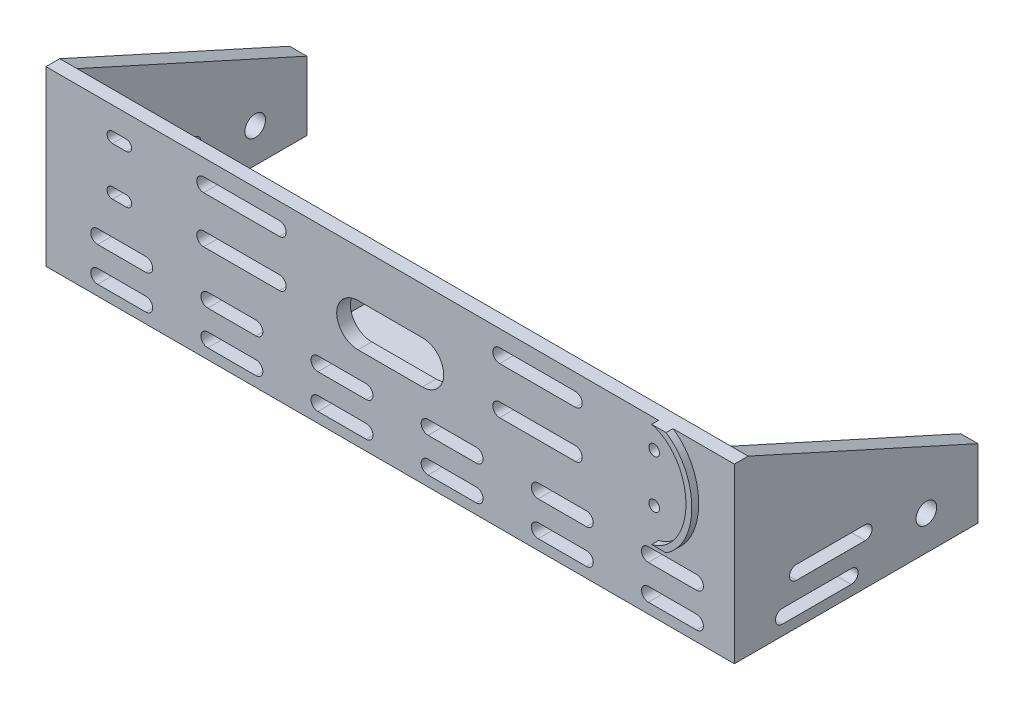
from build123d import *

# Parameters (mm, degrees)
SKETCH_1_W           = 200
SKETCH_1_H           = 200
EXTRUDE_1_DEPTH      = 4
SKETCH_2_W           = 200
SKETCH_2_H           = 200
CUT_EXTRUDE_1_DEPTH  = 10
CUT_EXTRUDE_2_DEPTH  = 10
SKETCH_4_R           = 1.2645
CUT_EXTRUDE_3_DEPTH  = 10
SKETCH_5_R           = 1.5645
SKETCH_5_R_2         = 1.2645
CUT_EXTRUDE_4_DEPTH  = 10
SKETCH_6_W           = 151.000000002
SKETCH_6_H           = 3
EXTRUDE_2_DEPTH      = 25
SKETCH_7_W           = 2
SKETCH_7_H           = 25
EXTRUDE_3_DEPTH      = 27.250481
CUT_EXTRUDE_5_DEPTH  = 155.418164294
SKETCH_9_W           = 25
SKETCH_9_H           = 3
EXTRUDE_4_DEPTH      = 19.5
SKETCH_10_W          = 25
SKETCH_10_H          = 3
EXTRUDE_5_DEPTH      = 19.5
SKETCH_11_R          = 1.5645
EXTRUDE_7_DEPTH      = 4
SKETCH_12_W          = 25
SKETCH_12_H          = 27.250481031
EXTRUDE_8_DEPTH      = 2
SKETCH_13_W          = 25
SKETCH_13_H          = 27.250481031
EXTRUDE_9_DEPTH      = 2
CUT_EXTRUDE_6_DEPTH  = 191.000000002
EXTRUDE_10_DEPTH     = 2
EXTRUDE_11_DEPTH     = 5
SKETCH_18_R          = 3
CUT_EXTRUDE_7_DEPTH  = 196.000000102
EXTRUDE_12_DEPTH     = 5
EXTRUDE_13_DEPTH     = 5
CUT_EXTRUDE_8_DEPTH  = 4
CUT_EXTRUDE_9_DEPTH  = 201.000000103
EXTRUDE_14_REACH     = 197
SKETCH_23_W          = 4
SKETCH_23_H          = 20
CUT_EXTRUDE_10_DEPTH = 4
CUT_EXTRUDE_11_DEPTH = 10
CUT_EXTRUDE_12_DEPTH = 2


with BuildPart() as part:
    # 草图1 → 凸台-拉伸1 (new body)
    with BuildSketch(Plane.XY):
        Rectangle(SKETCH_1_W, SKETCH_1_H)
    extrude(amount=EXTRUDE_1_DEPTH)

    # 草图2 → 切除-拉伸1 (cut)
    with BuildSketch(Plane.XY.offset(4)):
        Rectangle(SKETCH_2_W, SKETCH_2_H)
        with BuildLine():
            Line((-72.607629402, -10.530501842), (78.3923706, -10.530501842))
            add(Edge.make_bspline(
                [(78.3923706, -10.530501842), (78.393880387, -10.530501842), (78.399972524, -10.53049996), (78.40744519, -10.530491378), (78.459871908, -10.53038518), (78.562272047, -10.529406934), (78.709705475, -10.525745525), (78.867519351, -10.519395332), (79.011460862, -10.511271604), (79.163128689, -10.500500488), (79.314177324, -10.487542527), (79.48146243, -10.470336573), (79.625072974, -10.453078007), (79.714457573, -10.441104292), (79.828620547, -10.425256292), (80.06334743, -10.38961977), (80.447986875, -10.317063923), (80.804607354, -10.232716169), (81.010109931, -10.177223615), (81.271094972, -10.104267542), (81.653072128, -9.984548191), (82.204953821, -9.775873384), (82.733224047, -9.542742823), (83.080384914, -9.366425536), (83.363542253, -9.21272601), (83.594676625, -9.082189243), (83.944563941, -8.867794285), (84.303250262, -8.6290352), (84.536602386, -8.460897239), (84.67811474, -8.355000576), (84.868630399, -8.211197661), (85.217420243, -7.931169914), (85.693456263, -7.507965694), (86.160792675, -7.047893204), (86.463861613, -6.7174444), (86.705084475, -6.440891816), (86.900964007, -6.209064691), (87.089311918, -5.970595716), (87.276015542, -5.725693926), (87.363165679, -5.60758576), (87.566390889, -5.323258238), (87.807795061, -4.969931043), (88.153919224, -4.413295252), (88.489175038, -3.816720179), (88.696977954, -3.405825309), (88.827694465, -3.132985027), (88.961552796, -2.848834784), (89.186059359, -2.334343587), (89.452549767, -1.64230906), (89.611724622, -1.168522216), (89.709713744, -0.85457566), (89.732279416, -0.780564604), (89.818522908, -0.490886577), (89.938624245, -0.05740479), (90.042088798, 0.378887088), (90.130153117, 0.782983436), (90.218317016, 1.220249765), (90.306000365, 1.75393434), (90.388599777, 2.363273344), (90.454672066, 2.984147078), (90.505523692, 3.776258696), (90.517310025, 4.307283953), (90.517660945, 4.626339678), (90.517495564, 4.679554814), (90.515780492, 4.913414501), (90.507242486, 5.308832184), (90.486294809, 5.704553113), (90.458472193, 6.102064379), (90.420642115, 6.548963361), (90.352243586, 7.116156299), (90.254905763, 7.75569238), (90.139371739, 8.383847008), (89.968882042, 9.132540195), (89.834755229, 9.624444613), (89.712496066, 10.037493057), (89.659610942, 10.206799046), (89.584619088, 10.434523006), (89.498155072, 10.692437078), (89.405567032, 10.948461852), (89.25913666, 11.331116858), (89.091453274, 11.747163038), (88.907727045, 12.154890884), (88.709169844, 12.569926036), (88.509965198, 12.966174251), (88.184145506, 13.551639476), (87.825695748, 14.132919733), (87.570732294, 14.507134417), (87.306537888, 14.875920383), (87.169713303, 15.057612936), (87.007740906, 15.262115469), (86.85263991, 15.456477271), (86.556303726, 15.80793858), (86.125085813, 16.272847328), (85.824651865, 16.567072874), (85.641693274, 16.73762738), (85.483156881, 16.884005079), (85.320355757, 17.026808471), (85.140050328, 17.178288654), (84.960223922, 17.327161656), (84.776034828, 17.47097928), (84.610209439, 17.594731255), (84.414719243, 17.739353638), (84.046247727, 17.994801467), (83.693976719, 18.211827612), (83.35918282, 18.405532525), (83.199775918, 18.492622776), (82.958324133, 18.616725316), (82.721084383, 18.734959252), (82.47908929, 18.844576897), (82.28360727, 18.927283992), (82.122562456, 18.994454551), (81.830619699, 19.107790002), (81.438094679, 19.242379336), (81.174666844, 19.321024221), (81.003303504, 19.368456281), (80.874261012, 19.403327968), (80.687271896, 19.449919426), (80.452176284, 19.502940388), (80.217230736, 19.550401171), (79.952735177, 19.596492743), (79.686586193, 19.635507892), (79.480249043, 19.660045752), (79.27342215, 19.68086891), (79.066618193, 19.698045736), (78.778487967, 19.713854774), (78.563048758, 19.719177203), (78.441003264, 19.719867831), (78.425010406, 19.719925663), (78.4128902, 19.719962538), (78.400358023, 19.719976759), (78.3923706, 19.719979189)],
                knots=[0, 0, 0, 0, 4.447e-06, 1.5952e-05, 1.5952e-05, 0.000131611, 0.000272563, 0.000410637, 0.000581314, 0.00070686, 0.000885671, 0.001065892, 0.001244714, 0.001336472, 0.001336472, 0.001585108, 0.002037521, 0.002493259, 0.002672945, 0.002672945, 0.003303658, 0.003873505, 0.00444715, 0.005038552, 0.005038552, 0.005407894, 0.005828832, 0.006253752, 0.006682362, 0.006682362, 0.006780489, 0.007393979, 0.008018835, 0.008687071, 0.009355307, 0.009355307, 0.009778014, 0.010255315, 0.010255315, 0.010691779, 0.010691779, 0.01129905, 0.011973463, 0.012664373, 0.013364724, 0.013364724, 0.013578175, 0.014313322, 0.015058072, 0.015807425, 0.015807425, 0.016037669, 0.016037669, 0.016705905, 0.017374142, 0.017374142, 0.017943202, 0.018710614, 0.018998715, 0.019792218, 0.020588614, 0.021383559, 0.021383559, 0.021542504, 0.021542504, 0.022081494, 0.022720031, 0.022720031, 0.023266882, 0.024056504, 0.024428116, 0.025204624, 0.025971416, 0.026729449, 0.026729449, 0.027257473, 0.027257473, 0.02744224, 0.028065921, 0.028065921, 0.028660696, 0.029402393, 0.029402393, 0.030037035, 0.030729842, 0.031407102, 0.032075338, 0.032075338, 0.032751059, 0.032751059, 0.032851788, 0.033491451, 0.034123241, 0.034748283, 0.034748283, 0.034869809, 0.035391849, 0.035391849, 0.035569072, 0.036084756, 0.036084756, 0.036183433, 0.036807161, 0.037421228, 0.037421228, 0.037965125, 0.037965125, 0.038233217, 0.0387577, 0.0387577, 0.038864727, 0.039276448, 0.039685838, 0.040094173, 0.040094173, 0.04021696, 0.040496337, 0.040685967, 0.040968695, 0.041251278, 0.041532222, 0.041808011, 0.041886525, 0.042155666, 0.042417837, 0.042701929, 0.042736406, 0.042736406, 0.042743529, 0.042767118, 0.042767118, 0.042767118, 0.042767118], degree=3, weights=[1, 1, 1, 1, 1, 1, 1, 1, 1, 1, 1, 1, 1, 1, 1, 1, 1, 1, 1, 1, 1, 1, 1, 1, 1, 1, 1, 1, 1, 1, 1, 1, 1, 1, 1, 1, 1, 1, 1, 1, 1, 1, 1, 1, 1, 1, 1, 1, 1, 1, 1, 1, 1, 1, 1, 1, 1, 1, 1, 1, 1, 1, 1, 1, 1, 1, 1, 1, 1, 1, 1, 1, 1, 1, 1, 1, 1, 1, 1, 1, 1, 1, 1, 1, 1, 1, 1, 1, 1, 1, 1, 1, 1, 1, 1, 1, 1, 1, 1, 1, 1, 1, 1, 1, 1, 1, 1, 1, 1, 1, 1, 1, 1, 1, 1, 1, 1, 1, 1, 1, 1, 1, 1, 1, 1, 1, 1, 1, 1, 1, 1]))
            Line((78.3923706, 19.719979189), (-72.607629375, 19.719979189))
            add(Edge.make_bspline(
                [(-72.607629375, 19.719979189), (-72.609120172, 19.719979189), (-72.615171425, 19.719977341), (-72.62260188, 19.719968873), (-72.674722096, 19.719863926), (-72.776500065, 19.718897604), (-72.922708191, 19.71528854), (-73.079630746, 19.709020561), (-73.221910336, 19.701044557), (-73.372528292, 19.690430873), (-73.522502111, 19.677670516), (-73.689585503, 19.66060575), (-73.834809521, 19.643262006), (-73.926008075, 19.63109031), (-74.054727497, 19.613244863), (-74.293398118, 19.576584571), (-74.673465953, 19.503972802), (-75.01776578, 19.422625292), (-75.229158928, 19.365730944), (-75.301013956, 19.345543089), (-75.491311986, 19.291769051), (-75.857952952, 19.177121545), (-76.394457744, 18.976048344), (-76.926450095, 18.74254787), (-77.270811247, 18.568708782), (-77.540701481, 18.423189414), (-77.637731563, 18.368965121), (-77.859072885, 18.2408852), (-78.107287227, 18.090773474), (-78.467542626, 17.853600754), (-78.699867305, 17.688065511), (-78.833646464, 17.589153364), (-78.894320312, 17.543973614), (-79.088218209, 17.396702668), (-79.418377197, 17.131546447), (-79.861509288, 16.741153034), (-80.322082784, 16.292594649), (-80.619611571, 15.97235732), (-80.800646018, 15.767656173), (-80.835411621, 15.72787809), (-80.929758666, 15.618647104), (-81.097498586, 15.420442812), (-81.260079723, 15.216905528), (-81.463806874, 14.952213818), (-81.56231914, 14.819436441), (-81.689441537, 14.641825954), (-81.846409356, 14.419911538), (-82.124048959, 14.003054946), (-82.474431564, 13.422341759), (-82.774927648, 12.869904628), (-82.952816885, 12.51129492), (-83.102842739, 12.196649736), (-83.28205453, 11.804116753), (-83.446311209, 11.403633346), (-83.554879079, 11.121127163), (-83.609425129, 10.977297275), (-83.724594662, 10.660780526), (-83.815965555, 10.388727362), (-83.899969269, 10.125009541), (-83.937326505, 10.004370771), (-83.992432836, 9.819431857), (-84.073418882, 9.539048513), (-84.205057372, 9.042806728), (-84.359731928, 8.358462719), (-84.489986682, 7.645654594), (-84.590008199, 6.949971231), (-84.666177716, 6.24153145), (-84.717769727, 5.480511163), (-84.731462381, 4.947673985), (-84.732804636, 4.652175983), (-84.732869903, 4.623460211), (-84.732869903, 4.399700787), (-84.724780485, 3.876033569), (-84.676451959, 3.026094093), (-84.605354506, 2.374991648), (-84.552317644, 1.984296696), (-84.531797655, 1.838965975), (-84.470652269, 1.439913557), (-84.365296997, 0.858149211), (-84.198088679, 0.1134157), (-84.066183036, -0.376791513), (-83.985356037, -0.653412822), (-83.94528144, -0.78904762), (-83.903561265, -0.924255641), (-83.856678433, -1.071437688), (-83.767903648, -1.346180595), (-83.657581065, -1.660670459), (-83.556966369, -1.926126885), (-83.490484775, -2.099464784), (-83.346860633, -2.460440149), (-83.092677136, -3.03987542), (-82.772156641, -3.689159713), (-82.541583464, -4.107576984), (-82.400079699, -4.351103033), (-82.33318256, -4.464984105), (-82.175042356, -4.726375788), (-81.943600871, -5.087804529), (-81.747373232, -5.371765216), (-81.554675873, -5.640268291), (-81.459818679, -5.767918147), (-81.295390674, -5.981550655), (-81.095933069, -6.234420659), (-80.753626087, -6.63849695), (-80.327817351, -7.096021609), (-80.031026024, -7.386074809), (-79.773444849, -7.625828705), (-79.553653616, -7.823527688), (-79.20802993, -8.112912422), (-78.967610443, -8.29936161), (-78.655180789, -8.532138954), (-78.289277614, -8.7882164), (-77.909858247, -9.022127083), (-77.633289044, -9.181954844), (-77.538577346, -9.234857366), (-77.297562624, -9.364807638), (-76.99626455, -9.518534706), (-76.686647679, -9.658465977), (-76.399558623, -9.779729146), (-76.126068138, -9.889012513), (-75.701455126, -10.038178146), (-75.403324171, -10.127907614), (-75.176711301, -10.190532329), (-75.021102618, -10.231518747), (-74.791406143, -10.286310703), (-74.561033552, -10.335582961), (-74.330661775, -10.37924555), (-74.099073179, -10.41753804), (-73.89735567, -10.446010512), (-73.693381846, -10.470832691), (-73.487778575, -10.491920853), (-73.222930145, -10.51247218), (-72.957558651, -10.525576619), (-72.748362443, -10.52992818), (-72.647161877, -10.530442073), (-72.626361276, -10.530483957), (-72.619630604, -10.530496181), (-72.612207573, -10.530501842), (-72.607629402, -10.530501842)],
                knots=[0, 0, 0, 0, 4.386e-06, 1.5837e-05, 1.5837e-05, 0.000130651, 0.000270539, 0.000406605, 0.000576914, 0.000698994, 0.000877449, 0.001057414, 0.001236053, 0.001333619, 0.001333619, 0.001619655, 0.002045827, 0.002474984, 0.002667238, 0.002697787, 0.002697787, 0.003257622, 0.003848006, 0.004419103, 0.005003058, 0.005003058, 0.005334476, 0.005334476, 0.005764302, 0.006194128, 0.006608374, 0.006608374, 0.006688166, 0.006833182, 0.007332751, 0.00795098, 0.008598759, 0.00925525, 0.00925525, 0.009412489, 0.009412489, 0.009684356, 0.010183078, 0.010183078, 0.010672665, 0.010672665, 0.010831853, 0.011480628, 0.012166043, 0.012861197, 0.013365174, 0.013365174, 0.013904734, 0.014655834, 0.014655834, 0.014804903, 0.015113025, 0.015654973, 0.015654973, 0.015934148, 0.016030033, 0.016229494, 0.016804016, 0.017563946, 0.018332232, 0.018979733, 0.019674424, 0.020469263, 0.021261019, 0.021261019, 0.021346201, 0.021346201, 0.02192464, 0.022901272, 0.023881232, 0.023881232, 0.024080954, 0.024320504, 0.025089618, 0.025850088, 0.026599857, 0.026599857, 0.026705278, 0.027019343, 0.027019343, 0.027163228, 0.027875464, 0.028008671, 0.028008671, 0.028428639, 0.029167228, 0.029898321, 0.030591383, 0.030591383, 0.030736472, 0.030984281, 0.031498114, 0.032006855, 0.032006855, 0.032479846, 0.032479846, 0.032809184, 0.033439298, 0.034060241, 0.034674093, 0.034674093, 0.03510479, 0.03554946, 0.036007712, 0.036007712, 0.036710162, 0.037341331, 0.037341331, 0.03766566, 0.03766566, 0.03815906, 0.038674949, 0.038674949, 0.039081393, 0.03954613, 0.040008568, 0.040008568, 0.040249231, 0.040500362, 0.040754679, 0.041009689, 0.041263098, 0.041513325, 0.04165497, 0.041897483, 0.042132476, 0.042413821, 0.042612079, 0.042659983, 0.042659983, 0.04266232, 0.042675806, 0.042675806, 0.042675806, 0.042675806], degree=3, weights=[1, 1, 1, 1, 1, 1, 1, 1, 1, 1, 1, 1, 1, 1, 1, 1, 1, 1, 1, 1, 1, 1, 1, 1, 1, 1, 1, 1, 1, 1, 1, 1, 1, 1, 1, 1, 1, 1, 1, 1, 1, 1, 1, 1, 1, 1, 1, 1, 1, 1, 1, 1, 1, 1, 1, 1, 1, 1, 1, 1, 1, 1, 1, 1, 1, 1, 1, 1, 1, 1, 1, 1, 1, 1, 1, 1, 1, 1, 1, 1, 1, 1, 1, 1, 1, 1, 1, 1, 1, 1, 1, 1, 1, 1, 1, 1, 1, 1, 1, 1, 1, 1, 1, 1, 1, 1, 1, 1, 1, 1, 1, 1, 1, 1, 1, 1, 1, 1, 1, 1, 1, 1, 1, 1, 1, 1, 1, 1, 1, 1, 1, 1, 1, 1, 1, 1, 1, 1]))
        make_face(mode=Mode.SUBTRACT)
    extrude(amount=-CUT_EXTRUDE_1_DEPTH, mode=Mode.SUBTRACT)

    # 草图3 → 切除-拉伸2 (cut)
    with BuildSketch(Plane(origin=(0, 0, 0), x_dir=(-1, 0, 0), z_dir=(0, 0, -1))):
        with BuildLine():
            Line((-12.242370643, -6.205261327), (6.457629357, -6.205261327))
            ThreePointArc((6.457629357, -6.205261327), (12.657629357, -0.005261327), (6.457629357, 6.194738673))
            Line((6.457629357, 6.194738673), (-12.242370643, 6.194738673))
            ThreePointArc((-12.242370643, 6.194738673), (-18.442370643, -0.005261327), (-12.242370643, -6.205261327))
        make_face()
    extrude(amount=-CUT_EXTRUDE_2_DEPTH, mode=Mode.SUBTRACT)

    # 草图4 → 切除-拉伸3 (cut)
    with BuildSketch(Plane(origin=(0, 0, 0), x_dir=(-1, 0, 0), z_dir=(0, 0, -1))):
        with Locations((-79.592370643, 11.594738673)):
            Circle(SKETCH_4_R)
        with Locations((-79.592370643, -2.405261327)):
            Circle(SKETCH_4_R)
        with Locations((73.807629357, 11.594738673)):
            Circle(SKETCH_4_R)
        with Locations((73.807629357, -2.405261327)):
            Circle(SKETCH_4_R)
    extrude(amount=-CUT_EXTRUDE_3_DEPTH, mode=Mode.SUBTRACT)

    # 草图5 → 切除-拉伸4 (cut)
    with BuildSketch(Plane(origin=(0, 0, 0), x_dir=(-1, 0, 0), z_dir=(0, 0, -1))):
        with Locations((73.807629357, 11.594738673)):
            Circle(SKETCH_5_R)
        with Locations((73.807629357, 11.594738673)):
            Circle(SKETCH_5_R_2, mode=Mode.SUBTRACT)
        with Locations((73.807629357, -2.405261327)):
            Circle(SKETCH_5_R)
        with Locations((73.807629357, -2.405261327)):
            Circle(SKETCH_5_R_2, mode=Mode.SUBTRACT)
        with Locations((-79.592370643, -2.405261327)):
            Circle(SKETCH_5_R)
        with Locations((-79.592370643, 11.594738673)):
            Circle(SKETCH_5_R)
    extrude(amount=-CUT_EXTRUDE_4_DEPTH, mode=Mode.SUBTRACT)

    # 草图6 → 凸台-拉伸2 (add)
    with BuildSketch(Plane(origin=(0, 0, 0), x_dir=(-1, 0, 0), z_dir=(0, 0, -1))):
        with Locations((-2.892370599, -9.030501842)):
            Rectangle(SKETCH_6_W, SKETCH_6_H)
    extrude(amount=EXTRUDE_2_DEPTH)

    # 草图7 → 凸台-拉伸3 (add)
    with BuildSketch(Plane(origin=(0, -7.530501842, 0), x_dir=(1, 0, 0), z_dir=(0, 1, 0))):
        with Locations((24.685294291, 12.5)):
            Rectangle(SKETCH_7_W, SKETCH_7_H)
        with Locations((68.685294291, 12.5)):
            Rectangle(SKETCH_7_W, SKETCH_7_H)
        with Locations((-19.314705709, 12.5)):
            Rectangle(SKETCH_7_W, SKETCH_7_H)
        with Locations((-63.314705709, 12.5)):
            Rectangle(SKETCH_7_W, SKETCH_7_H)
    extrude(amount=EXTRUDE_3_DEPTH)

    # 草图8 → 切除-拉伸5 (cut, through all)
    with BuildSketch(Plane(origin=(69.685294291, 0, 0), x_dir=(0, 0, -1), z_dir=(1, 0, 0))):
        Polygon((0, 19.719979189), (25, -7.530501842), (25, 19.719979189), align=None)
    extrude(amount=-CUT_EXTRUDE_5_DEPTH, mode=Mode.SUBTRACT)

    # 草图9 → 凸台-拉伸4 (add)
    with BuildSketch(Plane(origin=(78.3923706, 0, 0), x_dir=(0, 0, -1), z_dir=(1, 0, 0))):
        with Locations((12.5, -9.030501842)):
            Rectangle(SKETCH_9_W, SKETCH_9_H)
    extrude(amount=EXTRUDE_4_DEPTH)

    # 草图10 → 凸台-拉伸5 (add)
    with BuildSketch(Plane.ZY.offset(72.607629402)):
        with Locations((-12.5, -9.030501842)):
            Rectangle(SKETCH_10_W, SKETCH_10_H)
    extrude(amount=EXTRUDE_5_DEPTH)

    # 草图11 → 凸台-拉伸7 (add)
    with BuildSketch(Plane(origin=(0, 0, 0), x_dir=(-1, 0, 0), z_dir=(0, 0, -1))):
        with BuildLine():
            Line((-85.66125426, -7.530501842), (-69.685294291, -7.530501842))
            Line((-69.685294291, -7.530501842), (-69.685294291, 19.719979189))
            Line((-69.685294291, 19.719979189), (-78.3923706, 19.719979189))
            Line((-78.3923706, 19.719979189), (-97.8923706, 19.719979189))
            Line((-97.8923706, 19.719979189), (-97.8923706, -7.530501842))
            Line((-97.8923706, -7.530501842), (-97.8923706, -10.530501842))
            Line((-97.8923706, -10.530501842), (-78.3923706, -10.530501842))
            add(Edge.make_bspline(
                [(-78.3923706, -10.530501842), (-78.393880387, -10.530501842), (-78.399972524, -10.53049996), (-78.40744519, -10.530491378), (-78.459871908, -10.53038518), (-78.562272047, -10.529406934), (-78.709705475, -10.525745525), (-78.867519351, -10.519395332), (-79.011460862, -10.511271604), (-79.163128689, -10.500500488), (-79.314177324, -10.487542527), (-79.48146243, -10.470336573), (-79.625072974, -10.453078007), (-79.714457573, -10.441104292), (-79.828620547, -10.425256292), (-80.06334743, -10.38961977), (-80.447986875, -10.317063923), (-80.804607354, -10.232716169), (-81.010109931, -10.177223615), (-81.271094972, -10.104267542), (-81.653072128, -9.984548191), (-82.204953821, -9.775873384), (-82.733224047, -9.542742823), (-83.080384914, -9.366425536), (-83.363542253, -9.21272601), (-83.594676625, -9.082189243), (-83.944563941, -8.867794285), (-84.303250262, -8.6290352), (-84.536602386, -8.460897239), (-84.67811474, -8.355000576), (-84.868630399, -8.211197661), (-85.211038803, -7.936293286), (-85.514395007, -7.667143377), (-85.66125426, -7.530501842)],
                knots=[0, 0, 0, 0, 4.447e-06, 1.5952e-05, 1.5952e-05, 0.000131611, 0.000272563, 0.000410637, 0.000581314, 0.00070686, 0.000885671, 0.001065892, 0.001244714, 0.001336472, 0.001336472, 0.001585108, 0.002037521, 0.002493259, 0.002672945, 0.002672945, 0.003303658, 0.003873505, 0.00444715, 0.005038552, 0.005038552, 0.005407894, 0.005828832, 0.006253752, 0.006682362, 0.006682362, 0.006780489, 0.007393979, 0.007994383, 0.007994383, 0.007994383, 0.007994383], degree=3, weights=[1, 1, 1, 1, 1, 1, 1, 1, 1, 1, 1, 1, 1, 1, 1, 1, 1, 1, 1, 1, 1, 1, 1, 1, 1, 1, 1, 1, 1, 1, 1, 1, 1, 1]))
        make_face()
        with Locations((-79.592370643, 11.594738673)):
            Circle(SKETCH_11_R, mode=Mode.SUBTRACT)
        with Locations((-79.592370643, -2.405261327)):
            Circle(SKETCH_11_R, mode=Mode.SUBTRACT)
        with BuildLine():
            Line((64.314705709, -7.530501842), (79.875858344, -7.530501842))
            add(Edge.make_bspline(
                [(79.875858344, -7.530501842), (79.770869403, -7.628144797), (79.552324591, -7.824640458), (79.20802993, -8.112912422), (78.967610443, -8.29936161), (78.655180789, -8.532138954), (78.289277614, -8.7882164), (77.909858247, -9.022127083), (77.633289044, -9.181954844), (77.538577346, -9.234857366), (77.297562624, -9.364807638), (76.99626455, -9.518534706), (76.686647679, -9.658465977), (76.399558623, -9.779729146), (76.126068138, -9.889012513), (75.701455126, -10.038178146), (75.403324171, -10.127907614), (75.176711301, -10.190532329), (75.021102618, -10.231518747), (74.791406143, -10.286310703), (74.561033552, -10.335582961), (74.330661775, -10.37924555), (74.099073179, -10.41753804), (73.89735567, -10.446010512), (73.693381846, -10.470832691), (73.487778575, -10.491920853), (73.222930145, -10.51247218), (72.957558651, -10.525576619), (72.748362443, -10.52992818), (72.647161877, -10.530442073), (72.626361276, -10.530483957), (72.619630604, -10.530496181), (72.612207573, -10.530501842), (72.607629402, -10.530501842)],
                knots=[0.034679221, 0.034679221, 0.034679221, 0.034679221, 0.03510479, 0.03554946, 0.036007712, 0.036007712, 0.036710162, 0.037341331, 0.037341331, 0.03766566, 0.03766566, 0.03815906, 0.038674949, 0.038674949, 0.039081393, 0.03954613, 0.040008568, 0.040008568, 0.040249231, 0.040500362, 0.040754679, 0.041009689, 0.041263098, 0.041513325, 0.04165497, 0.041897483, 0.042132476, 0.042413821, 0.042612079, 0.042659983, 0.042659983, 0.04266232, 0.042675806, 0.042675806, 0.042675806, 0.042675806], degree=3, weights=[1, 1, 1, 1, 1, 1, 1, 1, 1, 1, 1, 1, 1, 1, 1, 1, 1, 1, 1, 1, 1, 1, 1, 1, 1, 1, 1, 1, 1, 1, 1, 1, 1, 1]))
            Line((72.607629402, -10.530501842), (92.107629402, -10.530501842))
            Line((92.107629402, -10.530501842), (92.107629402, -7.530501842))
            Line((92.107629402, -7.530501842), (92.107629402, 19.719979189))
            Line((92.107629402, 19.719979189), (72.607629375, 19.719979189))
            Line((72.607629375, 19.719979189), (64.314705709, 19.719979189))
            Line((64.314705709, 19.719979189), (64.314705709, -7.530501842))
        make_face()
        with Locations((73.807629357, 11.594738673)):
            Circle(SKETCH_11_R, mode=Mode.SUBTRACT)
        with Locations((73.807629357, -2.405261327)):
            Circle(SKETCH_11_R, mode=Mode.SUBTRACT)
    extrude(amount=-EXTRUDE_7_DEPTH)

    # 草图12 → 凸台-拉伸8 (add)
    with BuildSketch(Plane(origin=(97.8923706, 0, 0), x_dir=(0, 0, -1), z_dir=(1, 0, 0))):
        with Locations((12.5, 6.094738674)):
            Rectangle(SKETCH_12_W, SKETCH_12_H)
    extrude(amount=-EXTRUDE_8_DEPTH)

    # 草图13 → 凸台-拉伸9 (add)
    with BuildSketch(Plane.ZY.offset(92.107629402)):
        with Locations((-12.5, 6.094738674)):
            Rectangle(SKETCH_13_W, SKETCH_13_H)
    extrude(amount=-EXTRUDE_9_DEPTH)

    # 草图14 → 切除-拉伸6 (cut, through all)
    with BuildSketch(Plane(origin=(97.8923706, 0, 0), x_dir=(0, 0, -1), z_dir=(1, 0, 0))):
        Polygon((0, 19.719979189), (25, -7.530501842), (25, 19.719979189), align=None)
    extrude(amount=-CUT_EXTRUDE_6_DEPTH, mode=Mode.SUBTRACT)

    # 草图15 → 凸台-拉伸10 (add)
    with BuildSketch(Plane.XY.offset(4)):
        with BuildLine():
            Line((-79.26705605, 19.719979189), (-75.058434673, 19.719979189))
            add(Edge.make_bspline(
                [(-75.058434673, 19.719979189), (-75.160324056, 19.694782078), (-75.706631825, 19.55073791), (-76.667619967, 19.212740646), (-77.894801871, 18.599225082), (-79.05929198, 17.827608518), (-80.457770993, 16.653810185), (-82.577793934, 14.21129148), (-84.525164222, 10.031908238), (-85.285746269, 4.608084744), (-84.529383017, -0.844443534), (-82.563599876, -5.040814161), (-80.153651059, -7.815042068), (-78.299917073, -9.206466034), (-76.661547883, -10.027672966), (-75.672355915, -10.371321577), (-75.149732483, -10.507952082), (-75.058434673, -10.530501842)],
                knots=[0.002364279, 0.002364279, 0.002364279, 0.002364279, 0.002667238, 0.004000857, 0.005334476, 0.006668095, 0.008001714, 0.010668952, 0.016003427, 0.021337903, 0.026672379, 0.032006855, 0.034674093, 0.037341331, 0.038674949, 0.040008568, 0.0402934, 0.0402934, 0.0402934, 0.0402934], degree=3))
            Line((-75.058434673, -10.530501842), (-79.266786568, -10.530501842))
            add(Edge.make_bspline(
                [(-79.26705605, 19.719979189), (-79.37845755, 19.648360464), (-79.64671165, 19.470290181), (-80.33581099, 18.976873188), (-81.667415293, 17.858950291), (-83.36862655, 15.895091148), (-84.890999562, 13.285419124), (-86.324766244, 9.518904929), (-87.005377243, 4.611709431), (-86.187053889, -1.323076644), (-84.029814318, -5.946067173), (-81.546064588, -8.809855489), (-80.074224087, -9.996616822), (-79.376932823, -10.459655534), (-79.266786568, -10.530501842)],
                knots=[0.00585724, 0.00585724, 0.00585724, 0.00585724, 0.006190645, 0.006668095, 0.008001714, 0.010668952, 0.013336189, 0.016003427, 0.021337903, 0.026672379, 0.032006855, 0.034674093, 0.036473164, 0.036806569, 0.036806569, 0.036806569, 0.036806569], degree=3))
        make_face()
        with BuildLine():
            Line((80.843175871, -10.530501842), (85.051527766, -10.530501842))
            add(Edge.make_bspline(
                [(85.051797248, 19.719979189), (85.163198748, 19.648360464), (85.431452848, 19.470290181), (86.120552188, 18.976873188), (87.452156491, 17.858950291), (89.153367748, 15.895091148), (90.67574076, 13.285419124), (92.109507442, 9.518904929), (92.790118441, 4.611709431), (91.971795087, -1.323076644), (89.814555516, -5.946067173), (87.330805785, -8.809855489), (85.858965285, -9.996616822), (85.161674021, -10.459655534), (85.051527766, -10.530501842)],
                knots=[0.00585724, 0.00585724, 0.00585724, 0.00585724, 0.006190645, 0.006668095, 0.008001714, 0.010668952, 0.013336189, 0.016003427, 0.021337903, 0.026672379, 0.032006855, 0.034674093, 0.036473164, 0.036806569, 0.036806569, 0.036806569, 0.036806569], degree=3))
            Line((85.051797248, 19.719979189), (80.843175871, 19.719979189))
            add(Edge.make_bspline(
                [(80.843175871, 19.719979189), (80.945065254, 19.694782078), (81.491373022, 19.55073791), (82.452361165, 19.212740646), (83.679543068, 18.599225082), (84.844033178, 17.827608518), (86.242512191, 16.653810185), (88.362535131, 14.21129148), (90.30990542, 10.031908238), (91.070487467, 4.608084744), (90.314124215, -0.844443534), (88.348341074, -5.040814161), (85.938392257, -7.815042068), (84.08465827, -9.206466034), (82.446289081, -10.027672966), (81.457097112, -10.371321577), (80.934473681, -10.507952082), (80.843175871, -10.530501842)],
                knots=[0.002364279, 0.002364279, 0.002364279, 0.002364279, 0.002667238, 0.004000857, 0.005334476, 0.006668095, 0.008001714, 0.010668952, 0.016003427, 0.021337903, 0.026672379, 0.032006855, 0.034674093, 0.037341331, 0.038674949, 0.040008568, 0.0402934, 0.0402934, 0.0402934, 0.0402934], degree=3))
        make_face()
    extrude(amount=EXTRUDE_10_DEPTH)

    # 草图17 → 凸台-拉伸11 (add)
    with BuildSketch(Plane(origin=(97.8923706, 0, 0), x_dir=(0, 0, -1), z_dir=(1, 0, 0))):
        Polygon((66.781558099, -30.530501842), (66.781558099, -10.530501842), (25, -10.530501842), (25, -7.530501842), (0, 19.719979189), (-4, 19.719979189), (-4, -10.530501842), (-4, -30.530501842), align=None)
    extrude_11 = extrude(amount=EXTRUDE_11_DEPTH)

    # 草图18 → 切除-拉伸7 (cut, through all)
    with BuildSketch(Plane(origin=(102.8923706, 0, 0), x_dir=(0, 0, -1), z_dir=(1, 0, 0))):
        with Locations((51.781558099, -20.530501842)):
            Circle(SKETCH_18_R)
    cut_extrude_7 = extrude(amount=-CUT_EXTRUDE_7_DEPTH, mode=Mode.SUBTRACT)

    # 镜向1: 凸台-拉伸11, 切除-拉伸7 across plane
    add(extrude_11.mirror(Plane.ZY.offset(-2.892370598)))
    add(cut_extrude_7.mirror(Plane.ZY.offset(-2.892370598)), mode=Mode.SUBTRACT)

    # 草图19 → 凸台-拉伸12 (add)
    with BuildSketch(Plane(origin=(102.8923706, 0, 0), x_dir=(0, 0, -1), z_dir=(1, 0, 0))):
        Polygon((0, 19.719979189), (66.781558099, -10.530501842), (25, -10.530501842), (25, -7.530501842), align=None)
    extrude(amount=-EXTRUDE_12_DEPTH)

    # 草图20 → 凸台-拉伸13 (add)
    with BuildSketch(Plane.ZY.offset(97.107629404)):
        Polygon((-66.781558099, -10.530501842), (0, 19.719979189), (-25, -7.530501842), (-25, -10.530501842), align=None)
    extrude(amount=-EXTRUDE_13_DEPTH)

    # 草图21 → 切除-拉伸8 (cut)
    with BuildSketch(Plane(origin=(0, 0, 0), x_dir=(-1, 0, 0), z_dir=(0, 0, -1))):
        with BuildLine():
            Line((-56.685294291, 14.907358931), (-34.685294291, 14.907358931))
            ThreePointArc((-34.685294291, 14.907358931), (-32.685294291, 12.907358931), (-34.685294291, 10.907358931))
            Line((-34.685294291, 10.907358931), (-56.685294291, 10.907358931))
            ThreePointArc((-56.685294291, 10.907358931), (-58.685294291, 12.907358931), (-56.685294291, 14.907358931))
        make_face()
        with BuildLine():
            Line((-56.685294291, -2.717881584), (-34.685294291, -2.717881584))
            ThreePointArc((-34.685294291, -2.717881584), (-32.685294291, -0.717881584), (-34.685294291, 1.282118416))
            Line((-34.685294291, 1.282118416), (-56.685294291, 1.282118416))
            ThreePointArc((-56.685294291, 1.282118416), (-58.685294291, -0.717881584), (-56.685294291, -2.717881584))
        make_face()
        with BuildLine():
            Line((51.314705709, -2.717881584), (29.314705709, -2.717881584))
            ThreePointArc((29.314705709, -2.717881584), (27.314705709, -0.717881584), (29.314705709, 1.282118416))
            Line((29.314705709, 1.282118416), (51.314705709, 1.282118416))
            ThreePointArc((51.314705709, 1.282118416), (53.314705709, -0.717881584), (51.314705709, -2.717881584))
        make_face()
        with BuildLine():
            Line((51.314705709, 14.907358931), (29.314705709, 14.907358931))
            ThreePointArc((29.314705709, 14.907358931), (27.314705709, 12.907358931), (29.314705709, 10.907358931))
            Line((29.314705709, 10.907358931), (51.314705709, 10.907358931))
            ThreePointArc((51.314705709, 10.907358931), (53.314705709, 12.907358931), (51.314705709, 14.907358931))
        make_face()
    extrude(amount=-CUT_EXTRUDE_8_DEPTH, mode=Mode.SUBTRACT)

    # 草图22 → 切除-拉伸9 (cut, through all)
    with BuildSketch(Plane(origin=(102.8923706, 0, 0), x_dir=(0, 0, -1), z_dir=(1, 0, 0))):
        with BuildLine():
            Line((9.945389525, -23.530501842), (29.945389525, -23.530501842))
            ThreePointArc((29.945389525, -23.530501842), (31.945389525, -25.530501842), (29.945389525, -27.530501842))
            Line((29.945389525, -27.530501842), (9.945389525, -27.530501842))
            ThreePointArc((9.945389525, -27.530501842), (7.945389525, -25.530501842), (9.945389525, -23.530501842))
        make_face()
        with BuildLine():
            Line((14.01752414, -14.540777212), (34.01752414, -14.540777212))
            ThreePointArc((34.01752414, -14.540777212), (36.01752414, -16.540777212), (34.01752414, -18.540777212))
            Line((34.01752414, -18.540777212), (14.01752414, -18.540777212))
            ThreePointArc((14.01752414, -18.540777212), (12.01752414, -16.540777212), (14.01752414, -14.540777212))
        make_face()
    extrude(amount=-CUT_EXTRUDE_9_DEPTH, mode=Mode.SUBTRACT)

    # 草图23 → 凸台-拉伸14 (add, up to next)
    with BuildSketch(Plane.ZY.offset(-97.8923706), mode=Mode.PRIVATE) as extrude_14_sk1:
        with Locations((2, -20.530501842)):
            Rectangle(SKETCH_23_W, SKETCH_23_H)
    extrude_14_tool1 = extrude(extrude_14_sk1.sketch, amount=EXTRUDE_14_REACH, mode=Mode.PRIVATE) - part.part
    add(extrude_14_tool1.solids().sort_by_distance((97.892371, -20.530502, 2))[0])

    # 草图24 → 切除-拉伸10 (cut)
    with BuildSketch(Plane.XY.offset(4)):
        with BuildLine():
            Line((-82.107629402, -23.530501842), (-68.107629402, -23.530501842))
            ThreePointArc((-68.107629402, -23.530501842), (-66.107629402, -25.530501842), (-68.107629402, -27.530501842))
            Line((-68.107629402, -27.530501842), (-82.107629402, -27.530501842))
            ThreePointArc((-82.107629402, -27.530501842), (-84.107629402, -25.530501842), (-82.107629402, -23.530501842))
        make_face()
        with BuildLine():
            Line((-82.107629402, -17.530501842), (-68.107629402, -17.530501842))
            ThreePointArc((-68.107629402, -17.530501842), (-66.107629402, -15.530501842), (-68.107629402, -13.530501842))
            Line((-68.107629402, -13.530501842), (-82.107629402, -13.530501842))
            ThreePointArc((-82.107629402, -13.530501842), (-84.107629402, -15.530501842), (-82.107629402, -17.530501842))
        make_face()
        with BuildLine():
            Line((-50.107629402, -23.530501842), (-36.107629402, -23.530501842))
            ThreePointArc((-36.107629402, -23.530501842), (-34.107629402, -25.530501842), (-36.107629402, -27.530501842))
            Line((-36.107629402, -27.530501842), (-50.107629402, -27.530501842))
            ThreePointArc((-50.107629402, -27.530501842), (-52.107629402, -25.530501842), (-50.107629402, -23.530501842))
        make_face()
        with BuildLine():
            Line((-50.107629402, -17.530501842), (-36.107629402, -17.530501842))
            ThreePointArc((-36.107629402, -17.530501842), (-34.107629402, -15.530501842), (-36.107629402, -13.530501842))
            Line((-36.107629402, -13.530501842), (-50.107629402, -13.530501842))
            ThreePointArc((-50.107629402, -13.530501842), (-52.107629402, -15.530501842), (-50.107629402, -17.530501842))
        make_face()
        with BuildLine():
            Line((-18.107629402, -23.530501842), (-4.107629402, -23.530501842))
            ThreePointArc((-4.107629402, -23.530501842), (-2.107629402, -25.530501842), (-4.107629402, -27.530501842))
            Line((-4.107629402, -27.530501842), (-18.107629402, -27.530501842))
            ThreePointArc((-18.107629402, -27.530501842), (-20.107629402, -25.530501842), (-18.107629402, -23.530501842))
        make_face()
        with BuildLine():
            Line((-18.107629402, -17.530501842), (-4.107629402, -17.530501842))
            ThreePointArc((-4.107629402, -17.530501842), (-2.107629402, -15.530501842), (-4.107629402, -13.530501842))
            Line((-4.107629402, -13.530501842), (-18.107629402, -13.530501842))
            ThreePointArc((-18.107629402, -13.530501842), (-20.107629402, -15.530501842), (-18.107629402, -17.530501842))
        make_face()
        with BuildLine():
            Line((13.892370598, -23.530501842), (27.892370598, -23.530501842))
            ThreePointArc((27.892370598, -23.530501842), (29.892370598, -25.530501842), (27.892370598, -27.530501842))
            Line((27.892370598, -27.530501842), (13.892370598, -27.530501842))
            ThreePointArc((13.892370598, -27.530501842), (11.892370598, -25.530501842), (13.892370598, -23.530501842))
        make_face()
        with BuildLine():
            Line((13.892370598, -17.530501842), (27.892370598, -17.530501842))
            ThreePointArc((27.892370598, -17.530501842), (29.892370598, -15.530501842), (27.892370598, -13.530501842))
            Line((27.892370598, -13.530501842), (13.892370598, -13.530501842))
            ThreePointArc((13.892370598, -13.530501842), (11.892370598, -15.530501842), (13.892370598, -17.530501842))
        make_face()
        with BuildLine():
            Line((45.892370598, -23.530501842), (59.892370598, -23.530501842))
            ThreePointArc((59.892370598, -23.530501842), (61.892370598, -25.530501842), (59.892370598, -27.530501842))
            Line((59.892370598, -27.530501842), (45.892370598, -27.530501842))
            ThreePointArc((45.892370598, -27.530501842), (43.892370598, -25.530501842), (45.892370598, -23.530501842))
        make_face()
        with BuildLine():
            Line((45.892370598, -17.530501842), (59.892370598, -17.530501842))
            ThreePointArc((59.892370598, -17.530501842), (61.892370598, -15.530501842), (59.892370598, -13.530501842))
            Line((59.892370598, -13.530501842), (45.892370598, -13.530501842))
            ThreePointArc((45.892370598, -13.530501842), (43.892370598, -15.530501842), (45.892370598, -17.530501842))
        make_face()
        with BuildLine():
            Line((77.892370598, -23.530501842), (91.892370598, -23.530501842))
            ThreePointArc((91.892370598, -23.530501842), (93.892370598, -25.530501842), (91.892370598, -27.530501842))
            Line((91.892370598, -27.530501842), (77.892370598, -27.530501842))
            ThreePointArc((77.892370598, -27.530501842), (75.892370598, -25.530501842), (77.892370598, -23.530501842))
        make_face()
        with BuildLine():
            Line((77.892370598, -17.530501842), (91.892370598, -17.530501842))
            ThreePointArc((91.892370598, -17.530501842), (93.892370598, -15.530501842), (91.892370598, -13.530501842))
            Line((91.892370598, -13.530501842), (77.892370598, -13.530501842))
            ThreePointArc((77.892370598, -13.530501842), (75.892370598, -15.530501842), (77.892370598, -17.530501842))
        make_face()
    extrude(amount=-CUT_EXTRUDE_10_DEPTH, mode=Mode.SUBTRACT)

    # 草图25 → 切除-拉伸11 (cut)
    with BuildSketch(Plane.XY.offset(4)):
        with BuildLine():
            ThreePointArc((-73.807629357, 10.030238673), (-72.243129357, 11.594738673), (-73.807629357, 13.159238673))
            Line((-73.807629357, 13.159238673), (-77.807629357, 13.159738673))
            ThreePointArc((-77.807629357, 13.159738661), (-79.372629344, 11.594738668), (-77.807629357, 10.029738674))
            Line((-77.807629357, 10.029738673), (-73.807629357, 10.030238673))
        make_face()
        with BuildLine():
            Line((-73.807629345, -0.840761327), (-77.807666049, -0.840276881))
            ThreePointArc((-77.807666049, -0.840276892), (-79.372650483, -2.405261332), (-77.807666049, -3.970245773))
            Line((-77.807666049, -3.970245773), (-73.807629328, -3.969761327))
            ThreePointArc((-73.807629328, -3.969761327), (-72.243129357, -2.405261318), (-73.807629345, -0.840761327))
        make_face()
    extrude(amount=-CUT_EXTRUDE_11_DEPTH, mode=Mode.SUBTRACT)

    # 草图26 → 切除-拉伸12 (cut)
    with BuildSketch(Plane.XY.offset(6)):
        with BuildLine():
            Line((-75.058434673, 19.719979189), (-79.26705605, 19.719979189))
            add(Edge.make_bspline(
                [(-79.26705605, 19.719979189), (-79.37845755, 19.648360464), (-79.64671165, 19.470290181), (-80.33581099, 18.976873188), (-81.667415293, 17.858950291), (-83.36862655, 15.895091148), (-84.890999562, 13.285419124), (-86.324766244, 9.518904929), (-87.005377243, 4.611709431), (-86.187053889, -1.323076644), (-84.029814318, -5.946067173), (-81.546064588, -8.809855489), (-80.074224087, -9.996616822), (-79.376932823, -10.459655534), (-79.266786566, -10.530501844)],
                knots=[0.00585724, 0.00585724, 0.00585724, 0.00585724, 0.006190645, 0.006668095, 0.008001714, 0.010668952, 0.013336189, 0.016003427, 0.021337903, 0.026672379, 0.032006855, 0.034674093, 0.036473164, 0.036806569, 0.036806569, 0.036806569, 0.036806569], degree=3))
            Line((-79.266786566, -10.530501844), (-75.058434673, -10.530501842))
            add(Edge.make_bspline(
                [(-75.058434673, -10.530501842), (-75.149732483, -10.507952082), (-75.672355915, -10.371321577), (-76.661547883, -10.027672966), (-78.299917073, -9.206466034), (-80.153651059, -7.815042068), (-82.563599876, -5.040814161), (-84.529383017, -0.844443534), (-85.285746269, 4.608084744), (-84.525164222, 10.031908238), (-82.577793934, 14.21129148), (-80.457770993, 16.653810185), (-79.05929198, 17.827608518), (-77.894801871, 18.599225082), (-76.667619967, 19.212740646), (-75.706631825, 19.55073791), (-75.160324056, 19.694782078), (-75.058434673, 19.719979189)],
                knots=[0.002364279, 0.002364279, 0.002364279, 0.002364279, 0.002649111, 0.00398273, 0.005316349, 0.007983586, 0.010650824, 0.0159853, 0.021319776, 0.026654252, 0.031988727, 0.034655965, 0.035989584, 0.037323203, 0.038656822, 0.039990441, 0.0402934, 0.0402934, 0.0402934, 0.0402934], degree=3))
        make_face()
    extrude(amount=-CUT_EXTRUDE_12_DEPTH, mode=Mode.SUBTRACT)


solid = part.part
